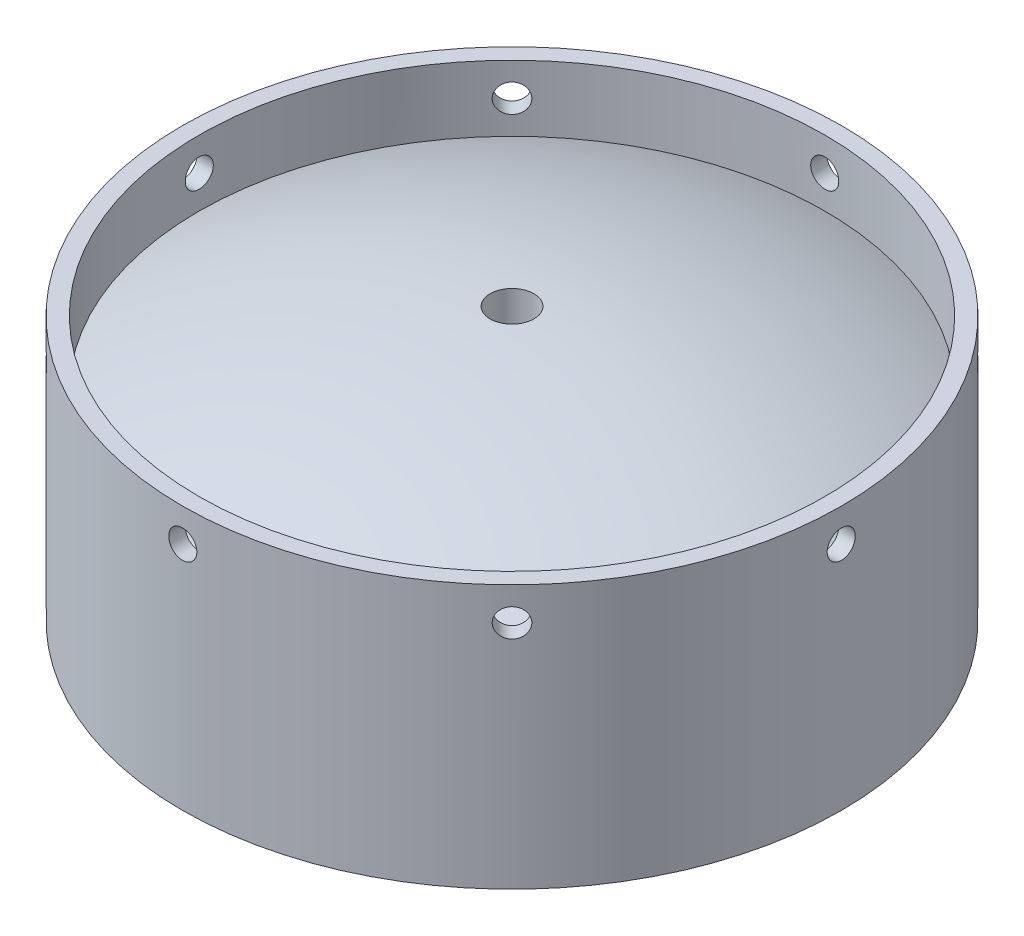
from build123d import *

# Parameters (mm, degrees)
F_3_0_213_DIAMETER_HOLE1_REACH  = 150.785
F_3_0_213_DIAMETER_HOLE1_BORE_R = 2.7051
CIRPATTERN1_COUNT               = 8


with BuildPart() as part:
    # Sketch1 → Revolve2 (revolve)
    with BuildSketch(Plane.XY, mode=Mode.PRIVATE) as revolve2_sk:
        with BuildLine():
            Line((-63.5, 0), (-63.5, 50.8))
            Line((-63.5, 50.8), (-60.325, 50.8))
            Line((-60.325, 50.8), (-60.325, 38.1))
            ThreePointArc((-60.325, 38.1), (-33.051376431, 48.308044626), (-4.2164, 52.382213484))
            Line((-4.2164, 52.382213484), (-4.2164, 45.393561735))
            ThreePointArc((-4.2164, 45.393561735), (-24.682494429, 43.041960117), (-44.499135715, 37.412414884))
            ThreePointArc((-44.499135715, 37.412414884), (-53.477680006, 30.42702697), (-56.874265357, 19.570088643))
            Line((-56.874265357, 19.570088643), (-60.325, 0))
            Line((-60.325, 0), (-63.5, 0))
        make_face()
    revolve(revolve2_sk.sketch.rotate(Axis((0, 127.060987048, 0), (0, -1, 0)), 270), axis=Axis((0, 127.060987048, 0), (0, -1, 0)))

    # 3 _0.213_ Diameter Hole1 bore (on position points) → 3 _0.213_ Diameter Hole1 (cut, up to next)
    with BuildSketch(Plane(origin=(0, 44.45, 63.5), x_dir=(1, 0, 0), z_dir=(0, 0, 1)), mode=Mode.PRIVATE) as f_3_0_213_diameter_hole1_sk1:
        Circle(F_3_0_213_DIAMETER_HOLE1_BORE_R)
    f_3_0_213_diameter_hole1_tool1 = extrude(f_3_0_213_diameter_hole1_sk1.sketch, amount=-F_3_0_213_DIAMETER_HOLE1_REACH, mode=Mode.PRIVATE) & part.part
    f_3_0_213_diameter_hole1 = f_3_0_213_diameter_hole1_tool1.solids().sort_by_distance((0, 44.45, 63.5))[0]
    add(f_3_0_213_diameter_hole1, mode=Mode.SUBTRACT)

    # CirPattern1: 3 _0.213_ Diameter Hole1 ×8 about axis
    cirpattern1_axis = Axis((0, 127.060987048, 0), (0, -1, 0))
    for i in range(1, CIRPATTERN1_COUNT):
        add(f_3_0_213_diameter_hole1.rotate(cirpattern1_axis, i * 360 / CIRPATTERN1_COUNT), mode=Mode.SUBTRACT)


solid = part.part
